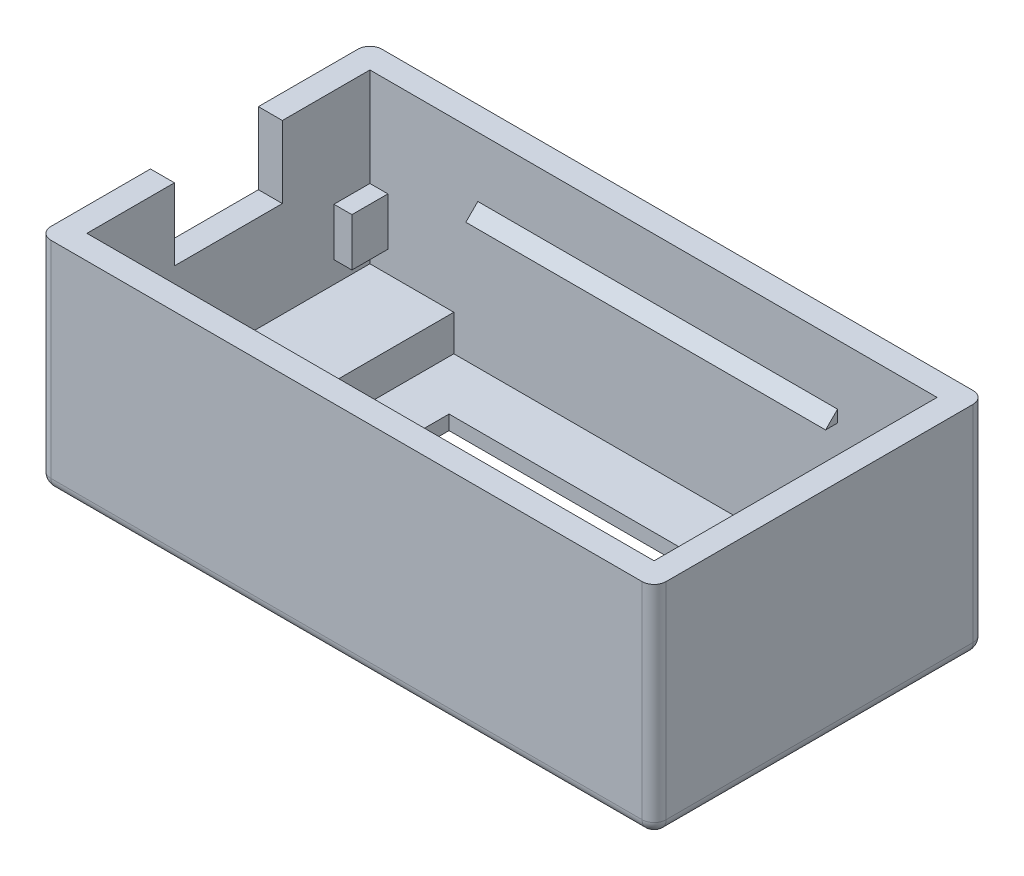
from build123d import *

# Parameters (mm, degrees)
SKETCH1_W                = 51.3
SKETCH1_H                = 27.6
SKETCH1_W_2              = 47.3
SKETCH1_H_2              = 23.6
EXTRUDE_THIN1_DEPTH      = 17
SKETCH2_W                = 51.3
SKETCH2_H                = 27.6
BOSS_EXTRUDE1_DEPTH      = 1.2
SKETCH3_W                = 30.5
SKETCH3_H                = 14.5
CUT_EXTRUDE1_DEPTH       = 10
SKETCH7_W                = 7
SKETCH7_H                = 23.6
SKETCH7_W_2              = 5.65
BOSS_EXTRUDE2_DEPTH      = 3
BOSS_EXTRUDE3_DEPTH      = 15
BOSS_EXTRUDE3_DEPTH_BACK = 15
FILLET1_R                = 1
SKETCH12_W               = 9
SKETCH12_H               = 12
CUT_EXTRUDE3_DEPTH       = 10
SKETCH14_W               = 1.5
SKETCH14_H               = 3
BOSS_EXTRUDE4_DEPTH      = 4


with BuildPart() as part:
    # Sketch1 → Extrude-Thin1 (new body)
    with BuildSketch(Plane(origin=(0, 0, 0), x_dir=(1, 0, 0), z_dir=(0, 1, 0))):
        with Locations((23.65, 11.8)):
            Rectangle(SKETCH1_W, SKETCH1_H)
        with Locations((23.65, 11.8)):
            Rectangle(SKETCH1_W_2, SKETCH1_H_2, mode=Mode.SUBTRACT)
    extrude(amount=EXTRUDE_THIN1_DEPTH)

    # Sketch2 → Boss-Extrude1 (add)
    with BuildSketch(Plane.XZ):
        with Locations((23.65, -11.8)):
            Rectangle(SKETCH2_W, SKETCH2_H)
    extrude(amount=BOSS_EXTRUDE1_DEPTH)

    # Sketch3 → Cut-Extrude1 (cut)
    with BuildSketch(Plane(origin=(0, 0, 0), x_dir=(1, 0, 0), z_dir=(0, 1, 0))):
        with Locations((26.4, 11.8)):
            Rectangle(SKETCH3_W, SKETCH3_H)
    extrude(amount=-CUT_EXTRUDE1_DEPTH, mode=Mode.SUBTRACT)

    # Sketch7 → Boss-Extrude2 (add)
    with BuildSketch(Plane(origin=(0, 0, 0), x_dir=(1, 0, 0), z_dir=(0, 1, 0))):
        with Locations((3.5, 11.8)):
            Rectangle(SKETCH7_W, SKETCH7_H)
        with Locations((44.475, 11.8)):
            Rectangle(SKETCH7_W_2, SKETCH7_H)
    extrude(amount=BOSS_EXTRUDE2_DEPTH)

    # Sketch9 → Boss-Extrude3 (add, two sides)
    with BuildSketch(Plane.ZY.offset(-24)) as boss_extrude3_sk:
        Polygon((-22.6, 11), (-23.6, 12), (-23.6, 11), align=None)
        Polygon((0, 12), (-1, 11), (0, 11), align=None)
    extrude(amount=BOSS_EXTRUDE3_DEPTH)
    extrude(boss_extrude3_sk.sketch, amount=-BOSS_EXTRUDE3_DEPTH_BACK)

    # Fillet1
    fillet1_edges = [part.edges().sort_by_distance(p)[0] for p in [
        (-2, -1.2, -11.8),
        (23.65, -1.2, -25.6),
        (49.3, -1.2, -11.8),
        (23.65, -1.2, 2),
        (-2, 7.9, -25.6),
        (49.3, 7.9, -25.6),
        (49.3, 7.9, 2),
        (-2, 7.9, 2),
    ]]
    fillet(fillet1_edges, radius=FILLET1_R)

    # Sketch12 → Cut-Extrude3 (cut)
    with BuildSketch(Plane.ZY.offset(2)):
        with Locations((-11.8, 17)):
            Rectangle(SKETCH12_W, SKETCH12_H)
    extrude(amount=-CUT_EXTRUDE3_DEPTH, mode=Mode.SUBTRACT)

    # Sketch14 → Boss-Extrude4 (add)
    with BuildSketch(Plane(origin=(0, 4.8, 0), x_dir=(1, 0, 0), z_dir=(0, 1, 0))):
        with Locations((0.75, 22.1)):
            Rectangle(SKETCH14_W, SKETCH14_H)
        with Locations((46.55, 22.1)):
            Rectangle(SKETCH14_W, SKETCH14_H)
        with Locations((46.55, 1.5)):
            Rectangle(SKETCH14_W, SKETCH14_H)
        with Locations((0.75, 1.5)):
            Rectangle(SKETCH14_W, SKETCH14_H)
    extrude(amount=BOSS_EXTRUDE4_DEPTH)


solid = part.part
